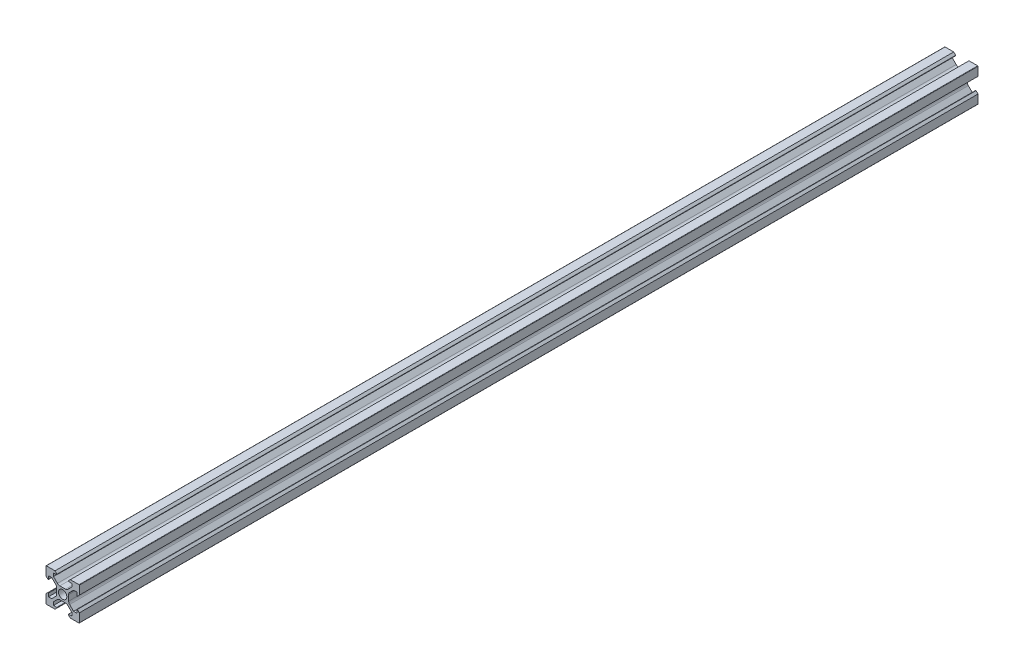
from build123d import *

# Parameters (mm, degrees)
ESBO_O1_R                = 2.5
RESSALTO_EXTRUS_O1_DEPTH = 540


with BuildPart() as part:
    # Esboço1 → Ressalto-extrusão1 (new body)
    with BuildSketch(Plane.XY):
        with BuildLine():
            Line((-4.6, -10), (-9.8, -10))
            ThreePointArc((-9.8, -10), (-9.941421356, -9.941421356), (-10, -9.8))
            Line((-10, -9.8), (-10, -4.6))
            Line((-10, -4.6), (-8.841421356, -3.441421356))
            ThreePointArc((-8.841421356, -3.441421356), (-8.623463314, -3.398066806), (-8.5, -3.582842712))
            Line((-8.5, -3.582842712), (-8.5, -5.5))
            Line((-8.5, -5.5), (-6.560660172, -5.5))
            Line((-6.560660172, -5.5), (-4.185786438, -3.125126266))
            ThreePointArc((-4.185786438, -3.125126266), (-3.752240935, -2.476279568), (-3.6, -1.710912703))
            Line((-3.6, -1.710912703), (-3.6, 1.710912703))
            ThreePointArc((-3.6, 1.710912703), (-3.752240935, 2.476279568), (-4.185786438, 3.125126266))
            Line((-4.185786438, 3.125126266), (-6.560660172, 5.5))
            Line((-6.560660172, 5.5), (-8.5, 5.5))
            Line((-8.5, 5.5), (-8.5, 3.582842712))
            ThreePointArc((-8.5, 3.582842712), (-8.623463314, 3.398066806), (-8.841421356, 3.441421356))
            Line((-8.841421356, 3.441421356), (-10, 4.6))
            Line((-10, 4.6), (-10, 9.8))
            ThreePointArc((-10, 9.8), (-9.941421356, 9.941421356), (-9.8, 10))
            Line((-9.8, 10), (-4.6, 10))
            Line((-4.6, 10), (-3.441421356, 8.841421356))
            ThreePointArc((-3.441421356, 8.841421356), (-3.398066806, 8.623463314), (-3.582842712, 8.5))
            Line((-3.582842712, 8.5), (-5.5, 8.5))
            Line((-5.5, 8.5), (-5.5, 6.560660172))
            Line((-5.5, 6.560660172), (-3.125126266, 4.185786438))
            ThreePointArc((-3.125126266, 4.185786438), (-2.476279568, 3.752240935), (-1.710912703, 3.6))
            Line((-1.710912703, 3.6), (1.710912703, 3.6))
            ThreePointArc((1.710912703, 3.6), (2.476279568, 3.752240935), (3.125126266, 4.185786438))
            Line((3.125126266, 4.185786438), (5.5, 6.560660172))
            Line((5.5, 6.560660172), (5.5, 8.5))
            Line((5.5, 8.5), (3.582842712, 8.5))
            ThreePointArc((3.582842712, 8.5), (3.398066806, 8.623463314), (3.441421356, 8.841421356))
            Line((3.441421356, 8.841421356), (4.6, 10))
            Line((4.6, 10), (9.8, 10))
            ThreePointArc((9.8, 10), (9.941421356, 9.941421356), (10, 9.8))
            Line((10, 9.8), (10, 4.6))
            Line((10, 4.6), (8.841421356, 3.441421356))
            ThreePointArc((8.841421356, 3.441421356), (8.623463314, 3.398066806), (8.5, 3.582842712))
            Line((8.5, 3.582842712), (8.5, 5.5))
            Line((8.5, 5.5), (6.560660172, 5.5))
            Line((6.560660172, 5.5), (4.185786438, 3.125126266))
            ThreePointArc((4.185786438, 3.125126266), (3.752240935, 2.476279568), (3.6, 1.710912703))
            Line((3.6, 1.710912703), (3.6, -1.710912703))
            ThreePointArc((3.6, -1.710912703), (3.752240935, -2.476279568), (4.185786438, -3.125126266))
            Line((4.185786438, -3.125126266), (6.560660172, -5.5))
            Line((6.560660172, -5.5), (8.5, -5.5))
            Line((8.5, -5.5), (8.5, -3.582842712))
            ThreePointArc((8.5, -3.582842712), (8.623463314, -3.398066806), (8.841421356, -3.441421356))
            Line((8.841421356, -3.441421356), (10, -4.6))
            Line((10, -4.6), (10, -9.8))
            ThreePointArc((10, -9.8), (9.941421356, -9.941421356), (9.8, -10))
            Line((9.8, -10), (4.6, -10))
            Line((4.6, -10), (3.441421356, -8.841421356))
            ThreePointArc((3.441421356, -8.841421356), (3.398066806, -8.623463314), (3.582842712, -8.5))
            Line((3.582842712, -8.5), (5.5, -8.5))
            Line((5.5, -8.5), (5.5, -6.560660172))
            Line((5.5, -6.560660172), (3.125126266, -4.185786438))
            ThreePointArc((3.125126266, -4.185786438), (2.476279568, -3.752240935), (1.710912703, -3.6))
            Line((1.710912703, -3.6), (-1.710912703, -3.6))
            ThreePointArc((-1.710912703, -3.6), (-2.476279568, -3.752240935), (-3.125126266, -4.185786438))
            Line((-3.125126266, -4.185786438), (-5.5, -6.560660172))
            Line((-5.5, -6.560660172), (-5.5, -8.5))
            Line((-5.5, -8.5), (-3.582842712, -8.5))
            ThreePointArc((-3.582842712, -8.5), (-3.398066806, -8.623463314), (-3.441421356, -8.841421356))
            Line((-3.441421356, -8.841421356), (-4.6, -10))
        make_face()
        Circle(ESBO_O1_R, mode=Mode.SUBTRACT)
    extrude(amount=RESSALTO_EXTRUS_O1_DEPTH)


solid = part.part
